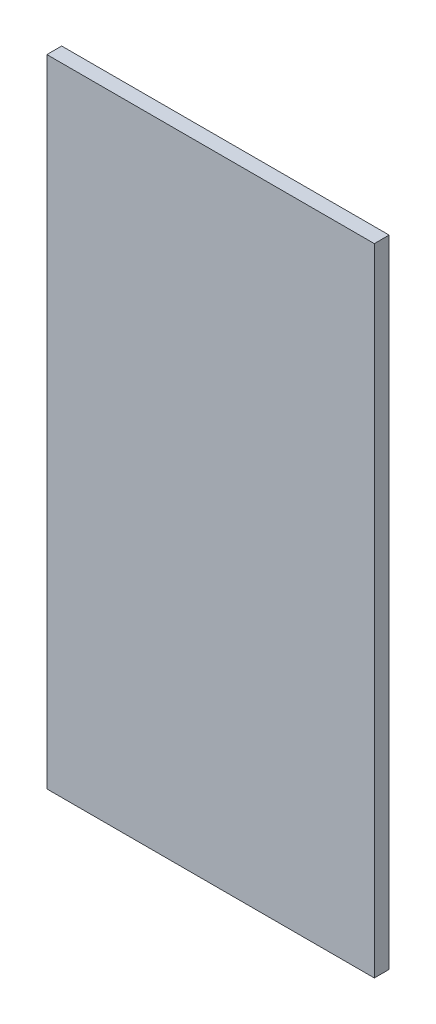
from build123d import *

# Parameters (mm, degrees)
SKETCH1_W           = 398
SKETCH1_H           = 773
BOSS_EXTRUDE1_DEPTH = 18


with BuildPart() as part:
    # Sketch1 → Boss-Extrude1 (new body)
    with BuildSketch(Plane.XY):
        Rectangle(SKETCH1_W, SKETCH1_H)
    extrude(amount=BOSS_EXTRUDE1_DEPTH)


solid = part.part
